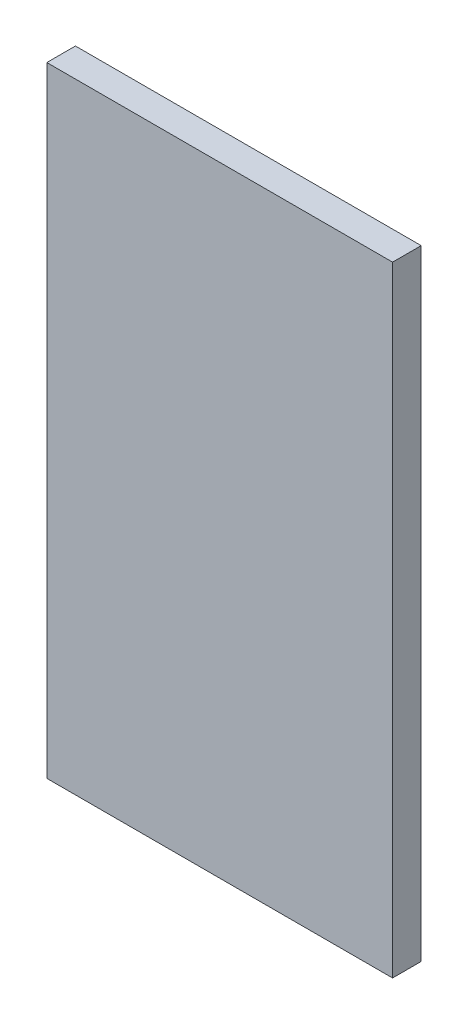
from build123d import *

# Parameters (mm, degrees)
SKETCH1_W           = 9.2075
SKETCH1_H           = 16.51
BOSS_EXTRUDE1_DEPTH = 0.762


with BuildPart() as part:
    # Sketch1 → Boss-Extrude1 (new body)
    with BuildSketch(Plane.XY):
        with Locations((-14.669644351, 41.878696913)):
            Rectangle(SKETCH1_W, SKETCH1_H)
    extrude(amount=BOSS_EXTRUDE1_DEPTH)


solid = part.part
